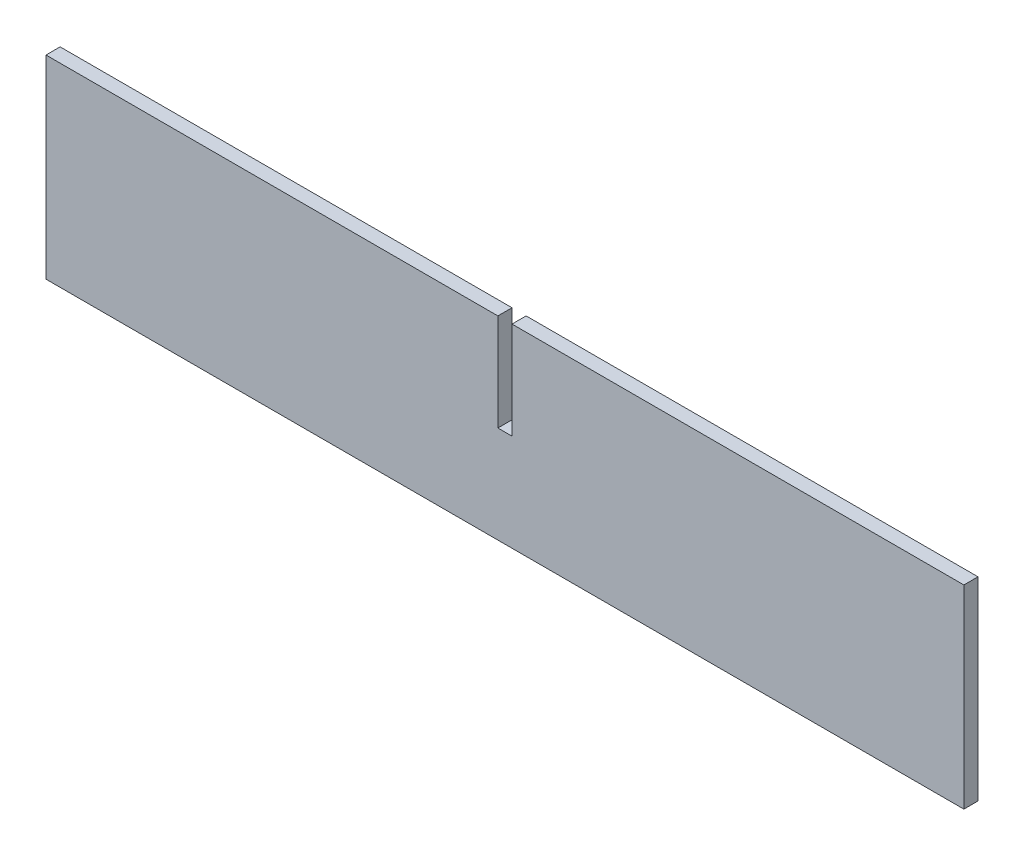
from build123d import *

# Parameters (mm, degrees)
BOSS_EXTRUDE1_DEPTH = 20


with BuildPart() as part:
    # Sketch2 → Boss-Extrude1 (new body)
    with BuildSketch(Plane.XY):
        Polygon((-650, 137.5), (-10, 137.5), (-10, 0), (10, 0), (10, 137.5), (650, 137.5), (650, -137.5), (-650, -137.5), align=None)
    extrude(amount=BOSS_EXTRUDE1_DEPTH)


solid = part.part
